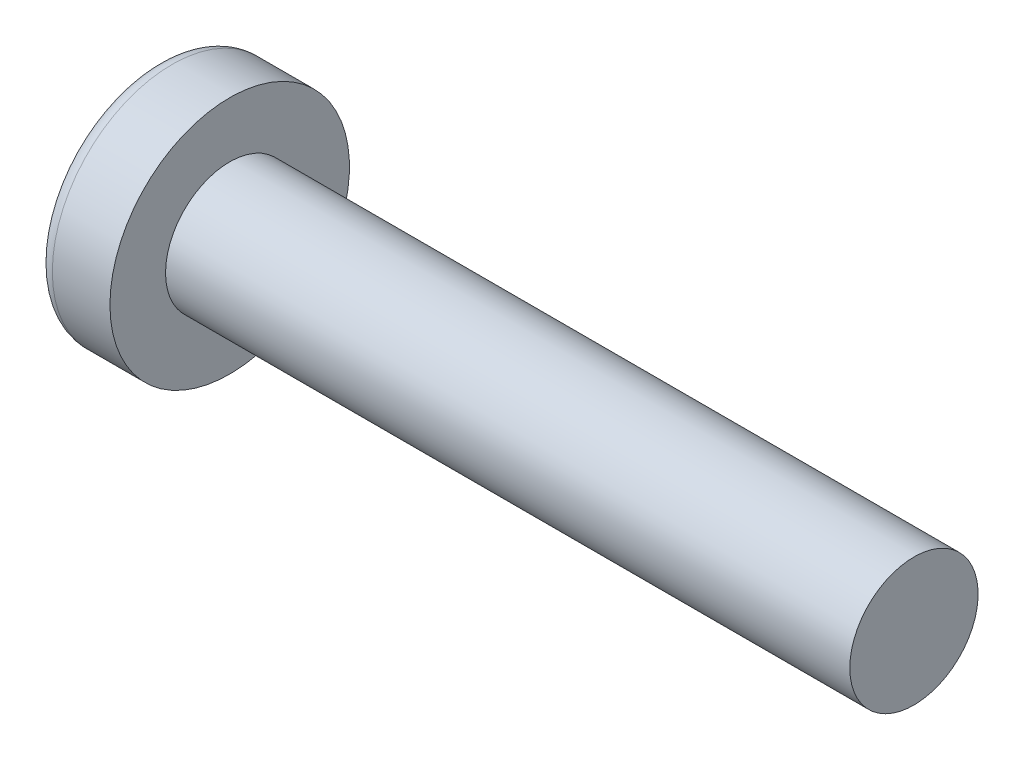
from build123d import *

# Parameters (mm, degrees)
SKETCH3_W         = 0.74
SKETCH3_H         = 2.9
SKETCH4_W         = 0.37
SKETCH4_H         = 0.37
CIRPATTERN1_COUNT = 2
CIRPATTERN1_ANGLE = 90


with BuildPart() as part:
    # BodySke → Base-Revolve (revolve)
    with BuildSketch(Plane.XY):
        with BuildLine():
            Line((2.4, 1.5), (2.4, 2.8))
            Line((2.4, 2.8), (1.053355856, 2.8))
            ThreePointArc((1.053355856, 2.8), (0.878072834, 2.754445324), (0.747150707, 2.629310345))
            ThreePointArc((0.747150707, 2.629310345), (0.190413403, 1.366702882), (0, 0))
            Line((0, 0), (18.4, 0))
            Line((18.4, 0), (18.4, 1.5))
            Line((18.4, 1.5), (2.4, 1.5))
        make_face()
    revolve(axis=Axis((-25.4, 0, 0), (1, 0, 0)))

    # Sketch3 → Cut-Loft1 section 0
    with BuildSketch(Plane(origin=(0, 0, 0), x_dir=(0, 0, -1), z_dir=(1, 0, 0))):
        Rectangle(SKETCH3_W, SKETCH3_H)
    # Sketch4 → Cut-Loft1 section 1
    with BuildSketch(Plane(origin=(1.76, 0, 0), x_dir=(0, 0, -1), z_dir=(1, 0, 0))):
        Rectangle(SKETCH4_W, SKETCH4_H)
    cut_loft1 = loft(mode=Mode.SUBTRACT)

    # CirPattern1: Cut-Loft1 ×2 about axis
    cirpattern1_axis = Axis((0, 0, 0), (1, 0, 0))
    for i in range(1, CIRPATTERN1_COUNT):
        add(cut_loft1.rotate(cirpattern1_axis, i * CIRPATTERN1_ANGLE / (CIRPATTERN1_COUNT - 1)), mode=Mode.SUBTRACT)


solid = part.part
